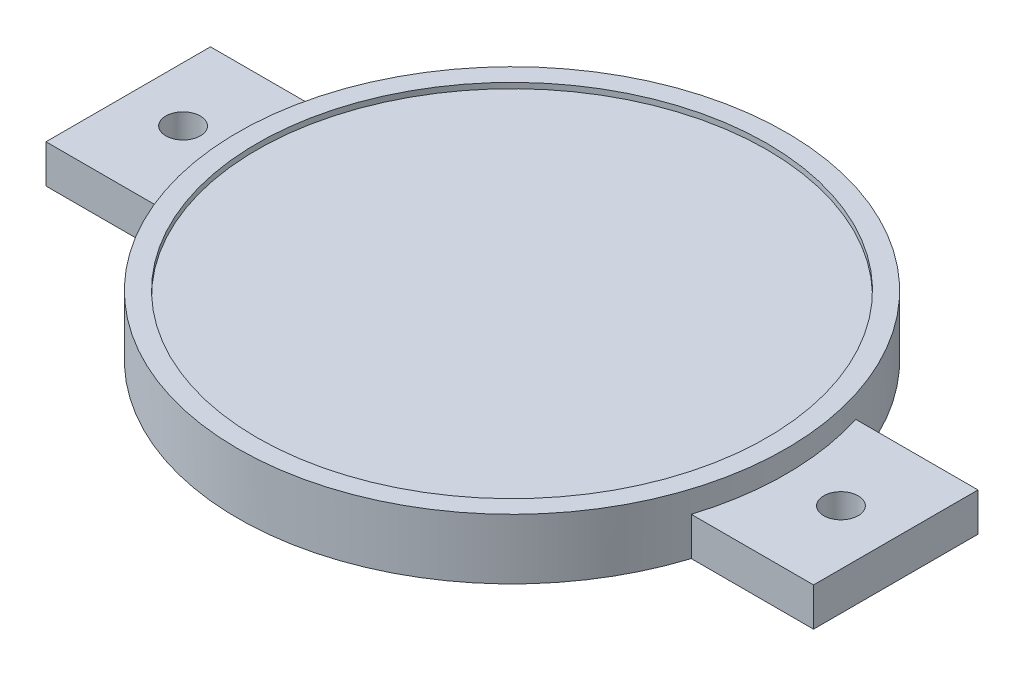
from build123d import *

# Parameters (mm, degrees)
SKETCH1_R           = 50
BOSS_EXTRUDE1_DEPTH = 10
SKETCH2_R           = 50
SKETCH2_R_2         = 46.5
BOSS_EXTRUDE2_DEPTH = 1
SKETCH3_R           = 47
CUT_EXTRUDE1_DEPTH  = 7
SKETCH4_R           = 3.15
BOSS_EXTRUDE3_DEPTH = 7


with BuildPart() as part:
    # Sketch1 → Boss-Extrude1 (new body)
    with BuildSketch(Plane(origin=(0, 0, 0), x_dir=(1, 0, 0), z_dir=(0, 1, 0))):
        Circle(SKETCH1_R)
    extrude(amount=BOSS_EXTRUDE1_DEPTH)

    # Sketch2 → Boss-Extrude2 (add)
    with BuildSketch(Plane(origin=(0, 10, 0), x_dir=(1, 0, 0), z_dir=(0, 1, 0))):
        Circle(SKETCH2_R)
        Circle(SKETCH2_R_2, mode=Mode.SUBTRACT)
    extrude(amount=BOSS_EXTRUDE2_DEPTH)

    # Sketch3 → Cut-Extrude1 (cut)
    with BuildSketch(Plane.XZ):
        Circle(SKETCH3_R)
    extrude(amount=-CUT_EXTRUDE1_DEPTH, mode=Mode.SUBTRACT)

    # Sketch4 → Boss-Extrude3 (add)
    with BuildSketch(Plane(origin=(0, 0, 0), x_dir=(1, 0, 0), z_dir=(0, 1, 0))):
        with BuildLine():
            Line((-47.696960071, 15), (-70, 15))
            Line((-70, 15), (-70, -15))
            Line((-70, -15), (-47.696960071, -15))
            ThreePointArc((-47.696960071, -15), (-50, 0), (-47.696960071, 15))
        make_face()
        with Locations((-60, 0)):
            Circle(SKETCH4_R, mode=Mode.SUBTRACT)
        with BuildLine():
            Line((47.696960071, -15), (70, -15))
            Line((70, -15), (70, 15))
            Line((70, 15), (47.696960071, 15))
            ThreePointArc((47.696960071, 15), (50, 0), (47.696960071, -15))
        make_face()
        with Locations((60, 0)):
            Circle(SKETCH4_R, mode=Mode.SUBTRACT)
    extrude(amount=BOSS_EXTRUDE3_DEPTH)


solid = part.part
